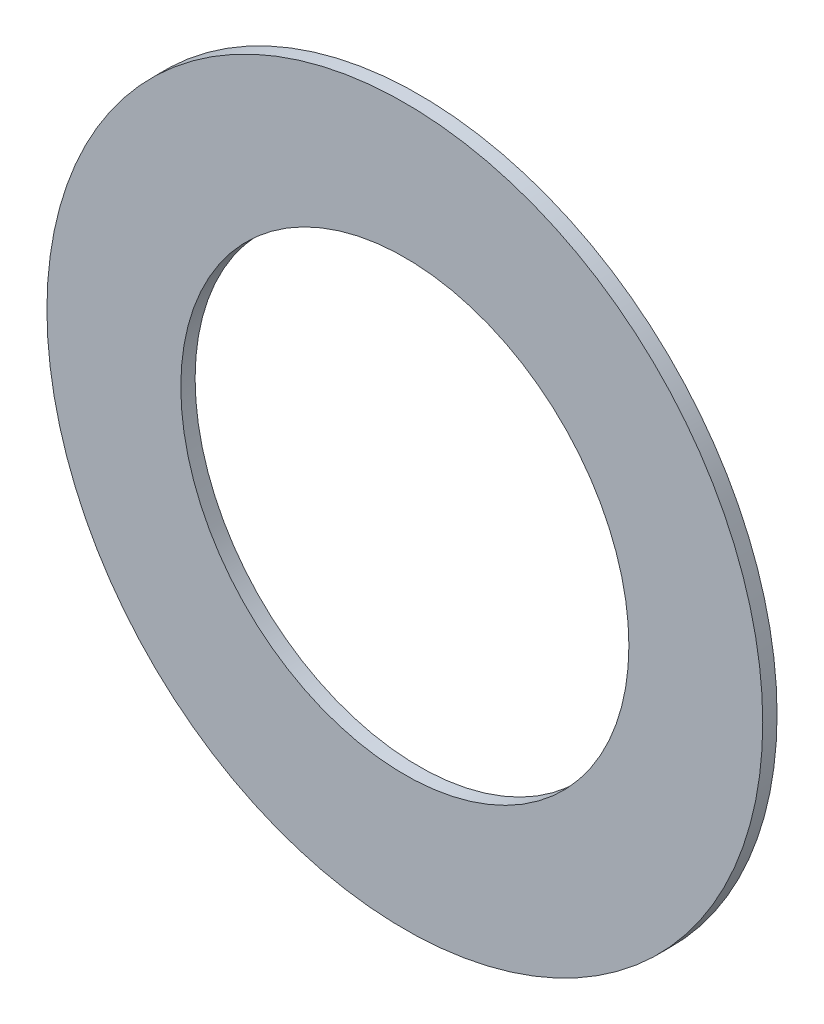
from build123d import *

# Parameters (mm, degrees)
SKETCH1_R           = 6.35
SKETCH1_R_2         = 3.9751
BOSS_EXTRUDE1_DEPTH = 0.254


with BuildPart() as part:
    # Sketch1 → Boss-Extrude1 (new body)
    with BuildSketch(Plane.XY):
        Circle(SKETCH1_R)
        Circle(SKETCH1_R_2, mode=Mode.SUBTRACT)
    extrude(amount=BOSS_EXTRUDE1_DEPTH)


solid = part.part
